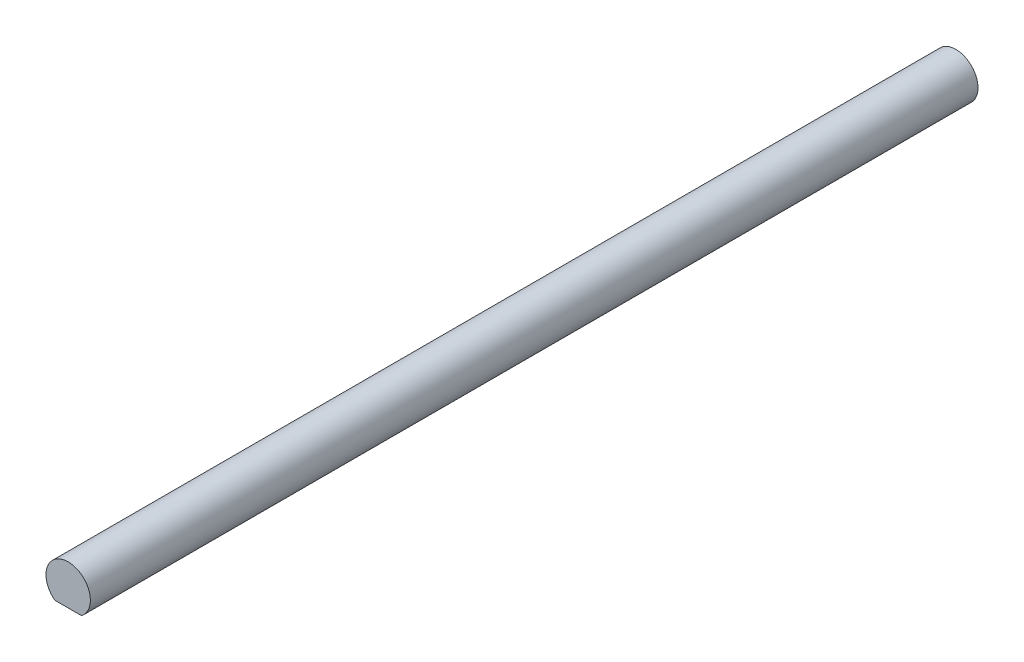
from build123d import *

# Parameters (mm, degrees)
BOSS_EXTRUDE1_DEPTH      = 63.5
BOSS_EXTRUDE1_DEPTH_BACK = 63.5


with BuildPart() as part:
    # Sketch1 → Boss-Extrude1 (new, two sides: drawn at the far end of the back side and taken through both)
    with BuildSketch(Plane.XY.offset(-BOSS_EXTRUDE1_DEPTH_BACK)):
        with BuildLine():
            Line((-1.905, -2.54), (1.905, -2.54))
            ThreePointArc((1.905, -2.54), (0, 3.175), (-1.905, -2.54))
        make_face()
    extrude(amount=BOSS_EXTRUDE1_DEPTH + BOSS_EXTRUDE1_DEPTH_BACK)


solid = part.part
